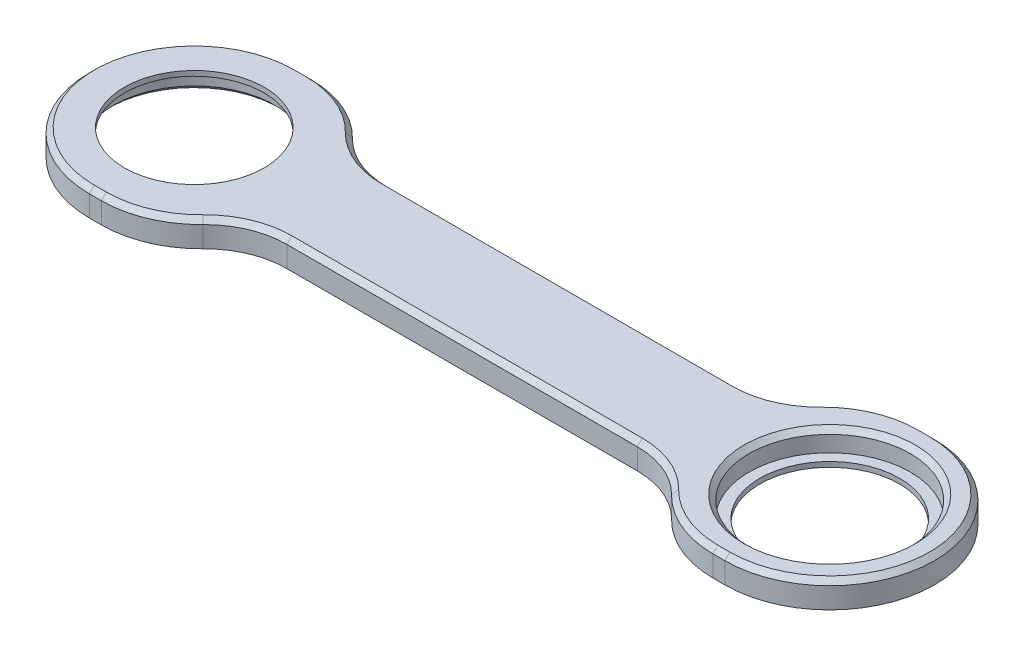
from build123d import *

# Parameters (mm, degrees)
SKETCH1_R           = 16.15
BOSS_EXTRUDE1_DEPTH = 5.2
FILLET1_R           = 20
CHAMFER1_SIZE       = 1
SKETCH2_R           = 19.025242353
SKETCH2_R_2         = 14
BOSS_EXTRUDE2_DEPTH = 1
SKETCH4_R           = 18.71529055
SKETCH4_R_2         = 14
BOSS_EXTRUDE3_DEPTH = 1
CHAMFER2_SIZE       = 1


with BuildPart() as part:
    # Sketch1 → Boss-Extrude1 (new body)
    with BuildSketch(Plane(origin=(0, 0, 0), x_dir=(1, 0, 0), z_dir=(0, 1, 0))):
        with BuildLine():
            Line((50.6952797, -21), (63.625, -21))
            ThreePointArc((63.625, -21), (84.625, 0), (63.625, 21))
            Line((63.625, 21), (50.6952797, 21))
            ThreePointArc((50.6952797, 21), (44.646090821, 13.026866227), (35.106613419, 10))
            Line((35.106613419, 10), (-35.106613419, 10))
            ThreePointArc((-35.106613419, 10), (-44.646090821, 13.026866227), (-50.6952797, 21))
            Line((-50.6952797, 21), (-63.625, 21))
            ThreePointArc((-63.625, 21), (-84.625, 0), (-63.625, -21))
            Line((-63.625, -21), (-50.6952797, -21))
            ThreePointArc((-50.6952797, -21), (-44.646090821, -13.026866227), (-35.106613419, -10))
            Line((-35.106613419, -10), (35.106613419, -10))
            ThreePointArc((35.106613419, -10), (44.646090821, -13.026866227), (50.6952797, -21))
        make_face()
        with Locations((-63.625, 0)):
            Circle(SKETCH1_R, mode=Mode.SUBTRACT)
        with Locations((63.625, 0)):
            Circle(SKETCH1_R, mode=Mode.SUBTRACT)
    extrude(amount=BOSS_EXTRUDE1_DEPTH)

    # Fillet1
    fillet1_edges = [part.edges().sort_by_distance(p)[0] for p in [
        (-50.6952797, 2.6, 21),
        (-50.6952797, 2.6, -21),
        (50.6952797, 2.6, -21),
        (50.6952797, 2.6, 21),
    ]]
    fillet(fillet1_edges, radius=FILLET1_R)

    # Chamfer1
    chamfer1_edges = [part.edges().sort_by_distance(p)[0] for p in [
        (62.433003391, 5.2, 21),
        (84.625, 5.2, 0),
        (62.433003391, 5.2, -21),
        (41.52534742, 5.2, -11.295776268),
        (0, 5.2, -10),
        (41.52534742, 5.2, 11.295776268),
        (-41.52534742, 5.2, -11.295776268),
        (-62.433003391, 5.2, -21),
        (-62.433003391, 5.2, 21),
        (-53.482236449, 5.2, 19.433705079),
        (-53.482236449, 5.2, -19.433705079),
        (-84.625, 5.2, 0),
        (53.482236449, 5.2, -19.433705079),
        (53.482236449, 5.2, 19.433705079),
        (-41.52534742, 5.2, 11.295776268),
        (0, 5.2, 10),
        (47.475, 5.2, 0),
    ]]
    chamfer(chamfer1_edges, length=CHAMFER1_SIZE)

    # Sketch2 → Boss-Extrude2 (add)
    with BuildSketch(Plane.XZ):
        with Locations((63.625, 0)):
            Circle(SKETCH2_R)
        with Locations((63.625, 0)):
            Circle(SKETCH2_R_2, mode=Mode.SUBTRACT)
    extrude(amount=-BOSS_EXTRUDE2_DEPTH)

    # Sketch4 → Boss-Extrude3 (add)
    with BuildSketch(Plane(origin=(0, 5.2, 0), x_dir=(1, 0, 0), z_dir=(0, 1, 0))):
        with Locations((-63.625, 0)):
            Circle(SKETCH4_R)
        with Locations((-63.625, 0)):
            Circle(SKETCH4_R_2, mode=Mode.SUBTRACT)
    extrude(amount=-BOSS_EXTRUDE3_DEPTH)

    # Chamfer2
    chamfer2_edges = [part.edges().sort_by_distance(p)[0] for p in [
        (-79.775, 0, 0),
    ]]
    chamfer(chamfer2_edges, length=CHAMFER2_SIZE)


solid = part.part
